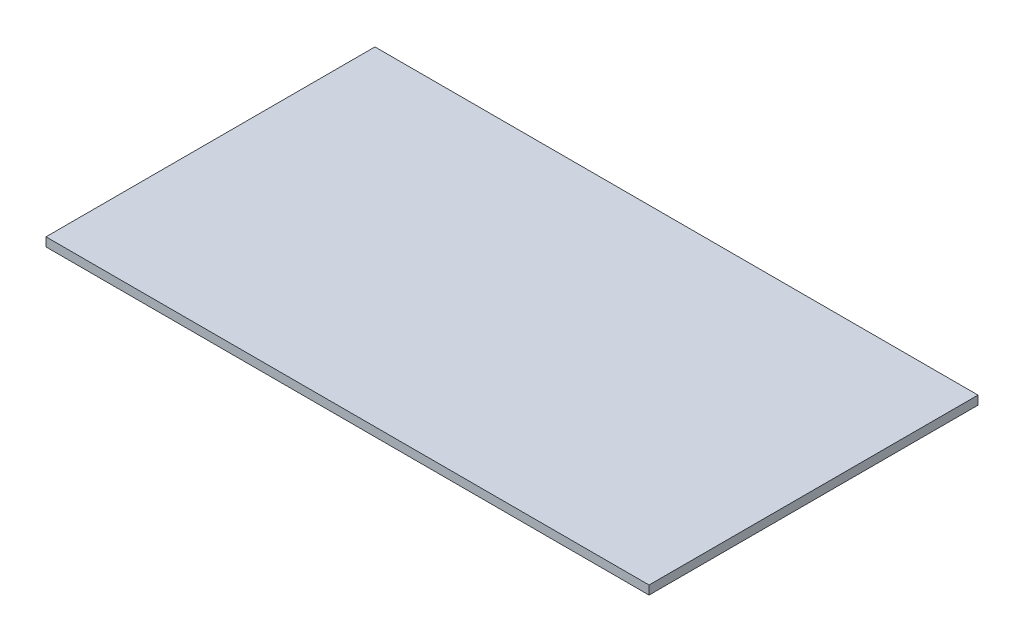
from build123d import *

# Parameters (mm, degrees)
SKETCH1_W           = 550
SKETCH1_H           = 300
BOSS_EXTRUDE1_DEPTH = 8


with BuildPart() as part:
    # Sketch1 → Boss-Extrude1 (new body)
    with BuildSketch(Plane(origin=(0, 0, 0), x_dir=(1, 0, 0), z_dir=(0, 1, 0))):
        Rectangle(SKETCH1_W, SKETCH1_H)
    extrude(amount=BOSS_EXTRUDE1_DEPTH)


solid = part.part
